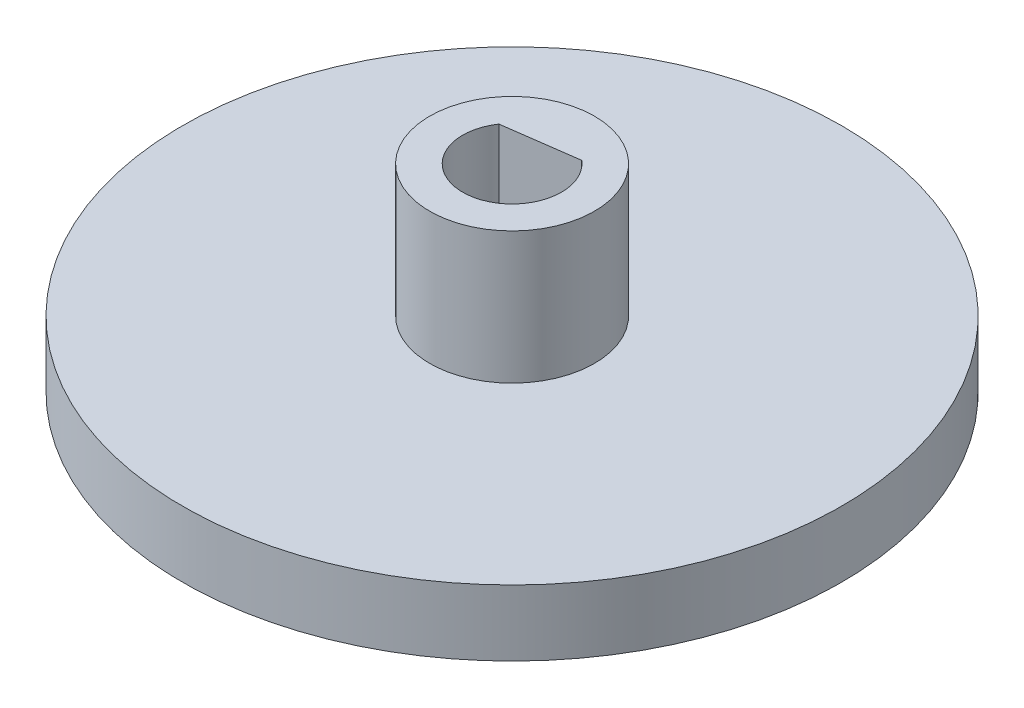
from build123d import *

# Parameters (mm, degrees)
SKETCH1_R           = 2.5
BOSS_EXTRUDE1_DEPTH = 10
SKETCH3_R           = 10
SKETCH3_R_2         = 2.5
BOSS_EXTRUDE2_DEPTH = 4
SKETCH4_R           = 10
SKETCH4_R_2         = 2.5
BOSS_EXTRUDE3_DEPTH = 2
SKETCH4_2_R         = 10
SKETCH4_2_R_2       = 2.5
CUT_EXTRUDE1_DEPTH  = 4


with BuildPart() as part:
    # Sketch1 → Boss-Extrude1 (new body)
    with BuildSketch(Plane(origin=(0, 0, 0), x_dir=(1, 0, 0), z_dir=(0, 1, 0))):
        Circle(SKETCH1_R)
        with BuildLine():
            Line((-1.242447099, 0.840431559), (0.968768208, 1.14513458))
            ThreePointArc((0.968768208, 1.14513458), (0.204756352, -1.485907091), (-1.242447099, 0.840431559))
        make_face(mode=Mode.SUBTRACT)
    extrude(amount=BOSS_EXTRUDE1_DEPTH)

    # Sketch3 → Boss-Extrude2 (add)
    with BuildSketch(Plane(origin=(0, 10, 0), x_dir=(1, 0, 0), z_dir=(0, 1, 0))):
        Circle(SKETCH3_R)
        Circle(SKETCH3_R_2, mode=Mode.SUBTRACT)
    extrude(amount=-BOSS_EXTRUDE2_DEPTH)

    # Sketch4 → Boss-Extrude3 (add)
    with BuildSketch(Plane.XZ.offset(-6)):
        Circle(SKETCH4_R)
        Circle(SKETCH4_R_2, mode=Mode.SUBTRACT)
    extrude(amount=BOSS_EXTRUDE3_DEPTH)

    # Sketch4_2 → Cut-Extrude1 (cut)
    with BuildSketch(Plane.XZ.offset(-6)):
        Circle(SKETCH4_2_R)
        Circle(SKETCH4_2_R_2, mode=Mode.SUBTRACT)
    extrude(amount=-CUT_EXTRUDE1_DEPTH, mode=Mode.SUBTRACT)


solid = part.part
